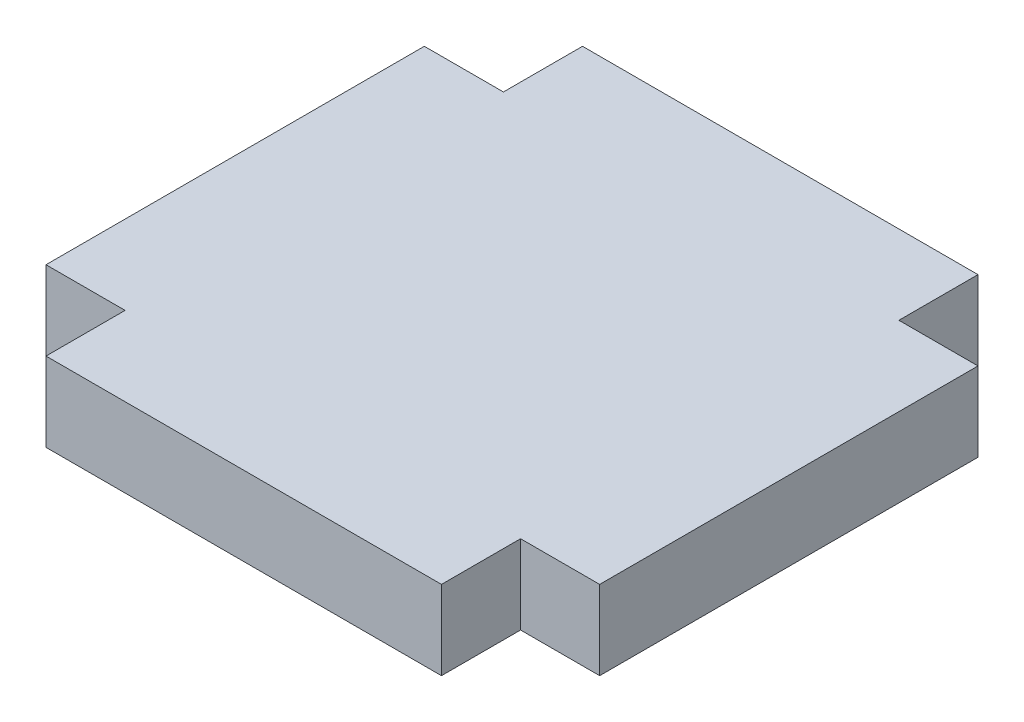
from build123d import *

# Parameters (mm, degrees)
BOSS_EXTRUDE1_DEPTH = 1.5


with BuildPart() as part:
    # Sketch1 → Boss-Extrude1 (new body, symmetric)
    with BuildSketch(Plane(origin=(0, 0, 0), x_dir=(1, 0, 0), z_dir=(0, 1, 0))):
        Polygon((-7.5, 10.175), (7.5, 10.175), (7.5, 7.175), (10.5, 7.175), (10.5, -7.175), (7.5, -7.175), (7.5, -10.175), (-7.5, -10.175), (-7.5, -7.175), (-10.5, -7.175), (-10.5, 7.175), (-7.5, 7.175), align=None)
    extrude(amount=BOSS_EXTRUDE1_DEPTH, both=True)


solid = part.part
